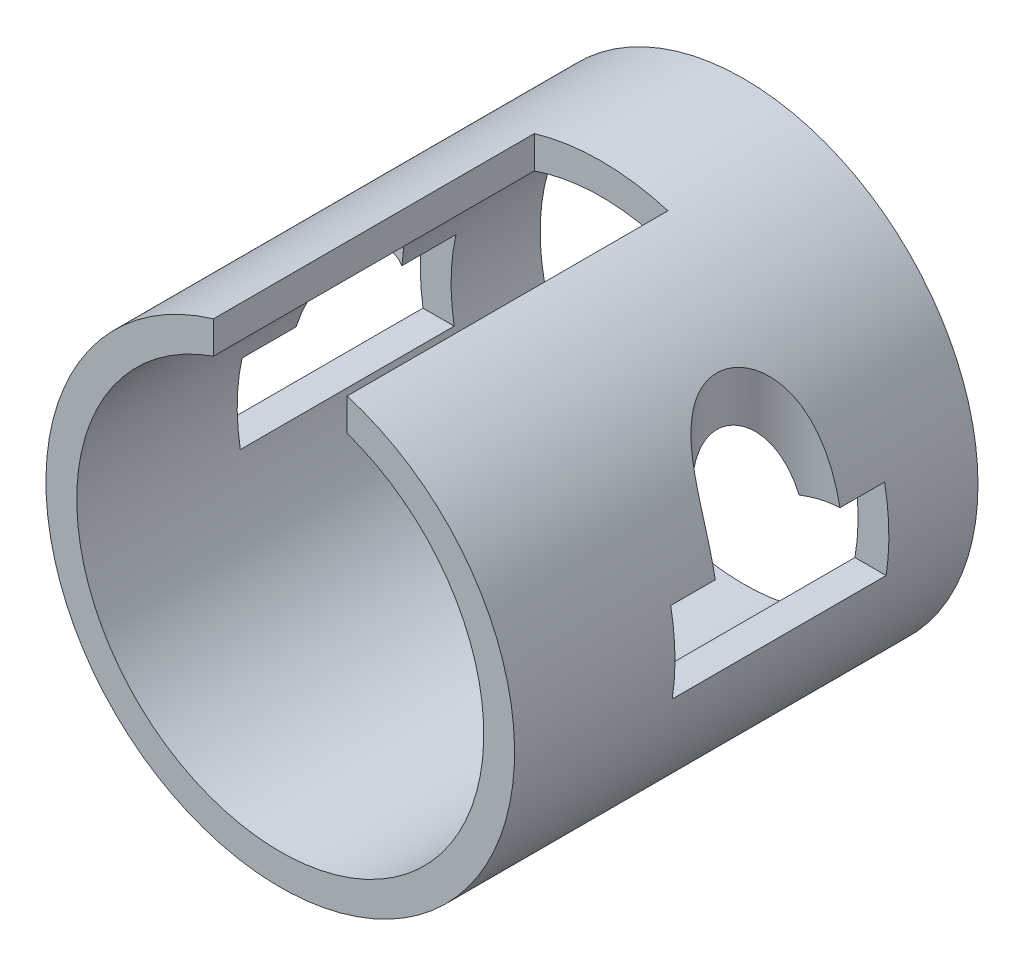
from build123d import *

# Parameters (mm, degrees)
SKETCH1_R               = 83.4771
SKETCH1_R_2             = 72.5043
BOSS_EXTRUDE1_DEPTH     = 82.55
SKETCH2_W               = 47.625
SKETCH2_H               = 114.3
CUT_EXTRUDE1_DEPTH      = 84.4771
SKETCH3_W               = 76.2
SKETCH3_H               = 25.4
CUT_EXTRUDE2_DEPTH      = 84.4771
CUT_EXTRUDE2_DEPTH_BACK = 84.4771
SKETCH4_R               = 22.225
CUT_EXTRUDE3_DEPTH      = 97.1771
SKETCH6_W               = 76.2
SKETCH6_H               = 3.175
CUT_EXTRUDE4_DEPTH      = 84.4771001
CUT_EXTRUDE4_DEPTH_BACK = 84.4771001


with BuildPart() as part:
    # Sketch1 → Boss-Extrude1 (new body, symmetric)
    with BuildSketch(Plane.XY):
        Circle(SKETCH1_R)
        Circle(SKETCH1_R_2, mode=Mode.SUBTRACT)
    extrude(amount=BOSS_EXTRUDE1_DEPTH, both=True)

    # Sketch2 → Cut-Extrude1 (cut, through all)
    with BuildSketch(Plane(origin=(0, 0, 0), x_dir=(1, 0, 0), z_dir=(0, 1, 0))):
        with Locations((0, -25.4)):
            Rectangle(SKETCH2_W, SKETCH2_H)
    extrude(amount=CUT_EXTRUDE1_DEPTH, mode=Mode.SUBTRACT)

    # Sketch3 → Cut-Extrude2 (cut, two sides)
    with BuildSketch(Plane(origin=(0, 0, 0), x_dir=(0, 0, -1), z_dir=(1, 0, 0))) as cut_extrude2_sk:
        with Locations((12.7, 0)):
            Rectangle(SKETCH3_W, SKETCH3_H)
    extrude(amount=CUT_EXTRUDE2_DEPTH, mode=Mode.SUBTRACT)
    extrude(cut_extrude2_sk.sketch, amount=-CUT_EXTRUDE2_DEPTH_BACK, mode=Mode.SUBTRACT)

    # Sketch4 → Cut-Extrude3 (cut, through all)
    with BuildSketch(Plane(origin=(0, -12.7, 0), x_dir=(1, 0, 0), z_dir=(0, 1, 0))):
        with Locations((-82.505370882, 12.7)):
            Circle(SKETCH4_R)
        with Locations((82.505370882, 12.7)):
            Circle(SKETCH4_R)
    extrude(amount=CUT_EXTRUDE3_DEPTH, mode=Mode.SUBTRACT)

    # Sketch6 → Cut-Extrude4 (cut, two sides)
    with BuildSketch(Plane(origin=(0, 0, 0), x_dir=(0, 0, -1), z_dir=(1, 0, 0))) as cut_extrude4_sk:
        with Locations((12.7, 14.2875)):
            Rectangle(SKETCH6_W, SKETCH6_H)
    extrude(amount=CUT_EXTRUDE4_DEPTH, mode=Mode.SUBTRACT)
    extrude(cut_extrude4_sk.sketch, amount=-CUT_EXTRUDE4_DEPTH_BACK, mode=Mode.SUBTRACT)


solid = part.part
